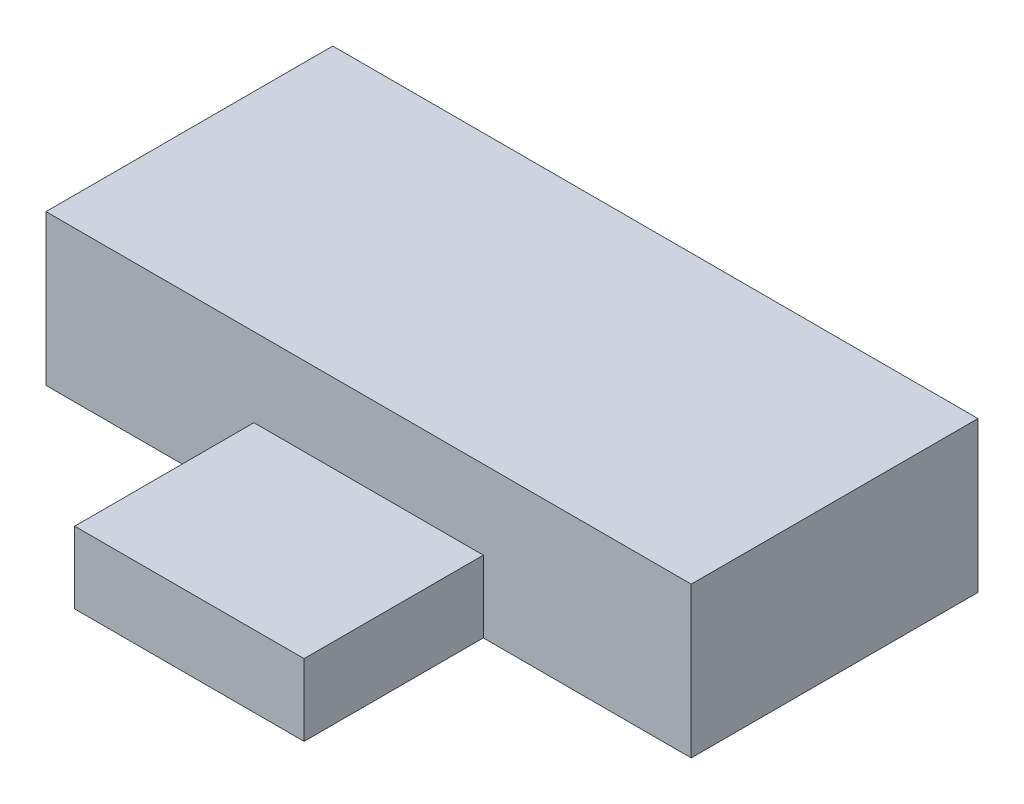
from build123d import *

# Parameters (mm, degrees)
ESQUISSE1_W        = 18
ESQUISSE1_H        = 8
BOSS_EXTRU_1_DEPTH = 4.2
ESQUISSE2_W        = 6.4
ESQUISSE2_H        = 2
BOSS_EXTRU_2_DEPTH = 5


with BuildPart() as part:
    # Esquisse1 → Boss.-Extru.1 (new body)
    with BuildSketch(Plane(origin=(0, 0, 0), x_dir=(1, 0, 0), z_dir=(0, 1, 0))):
        Rectangle(ESQUISSE1_W, ESQUISSE1_H)
    extrude(amount=BOSS_EXTRU_1_DEPTH)

    # Esquisse2 → Boss.-Extru.2 (add)
    with BuildSketch(Plane.XY.offset(4)):
        with Locations((0, 1)):
            Rectangle(ESQUISSE2_W, ESQUISSE2_H)
    extrude(amount=BOSS_EXTRU_2_DEPTH)


solid = part.part
